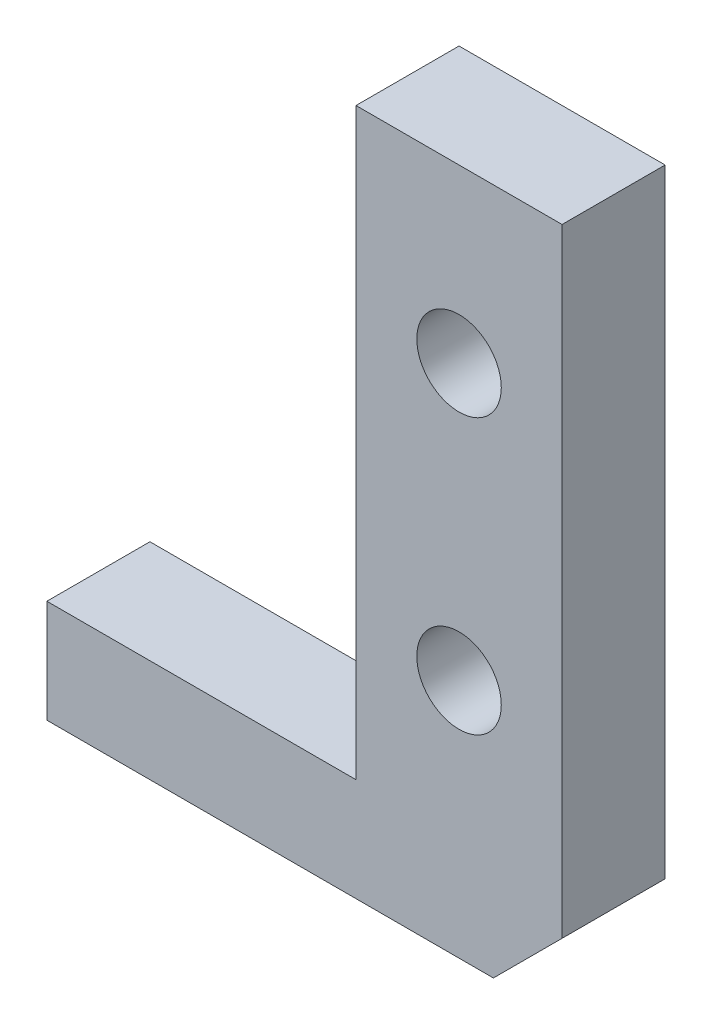
from build123d import *

# Parameters (mm, degrees)
BOSS_EXTRUDE1_DEPTH = 3
SKETCH2_R           = 1.23
CUT_EXTRUDE1_DEPTH  = 4


with BuildPart() as part:
    # Sketch1 → Boss-Extrude1 (new body)
    with BuildSketch(Plane.XY):
        Polygon((0, 0), (13, 0), (15, 2), (15, 20), (9, 20), (9, 3), (0, 3), align=None)
    extrude(amount=BOSS_EXTRUDE1_DEPTH)

    # Sketch2 → Cut-Extrude1 (cut, through all)
    with BuildSketch(Plane.XY.offset(3)):
        with Locations((12, 15)):
            Circle(SKETCH2_R)
        with Locations((12, 7)):
            Circle(SKETCH2_R)
    extrude(amount=-CUT_EXTRUDE1_DEPTH, mode=Mode.SUBTRACT)


solid = part.part
